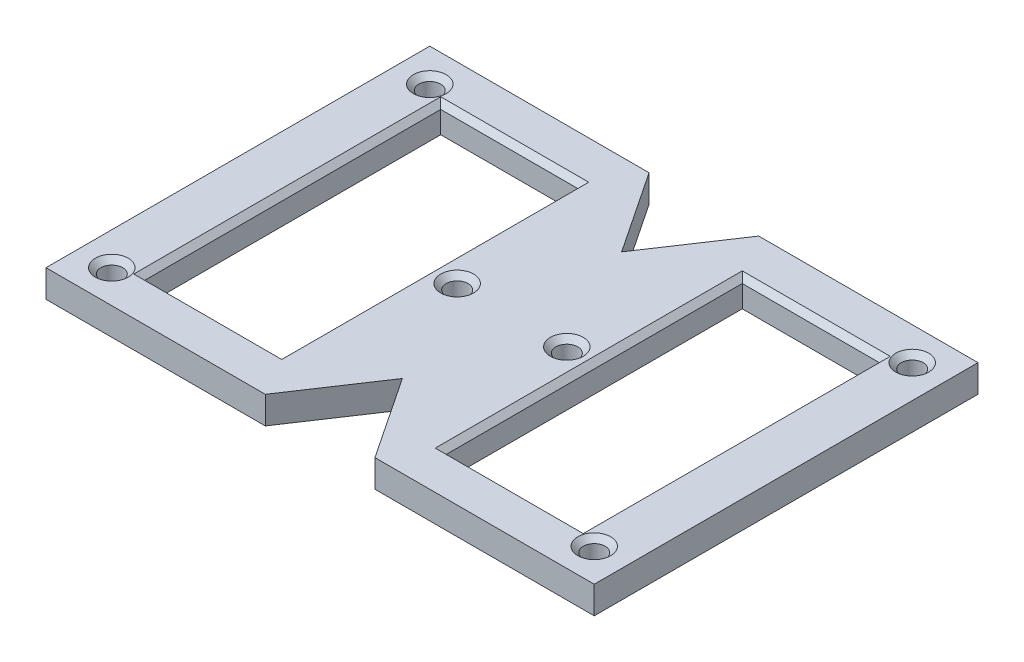
from build123d import *

# Parameters (mm, degrees)
CROQUIS1_W              = 100
CROQUIS1_H              = 70
SALIENTE_EXTRUIR1_DEPTH = 5
CROQUIS3_R              = 2
CORTAR_EXTRUIR2_DEPTH   = 6
CROQUIS6_R              = 2
CORTAR_EXTRUIR3_DEPTH   = 6
CROQUIS7_W              = 25
CROQUIS7_H              = 54
CORTAR_EXTRUIR4_DEPTH   = 6
CORTAR_EXTRUIR5_DEPTH   = 6
CHAFL_N1_SIZE           = 1


with BuildPart() as part:
    # Croquis1 → Saliente-Extruir1 (new body)
    with BuildSketch(Plane(origin=(0, 0, 0), x_dir=(1, 0, 0), z_dir=(0, 1, 0))):
        Rectangle(CROQUIS1_W, CROQUIS1_H)
    extrude(amount=SALIENTE_EXTRUIR1_DEPTH)

    # Croquis3 → Cortar-Extruir2 (cut, through all)
    with BuildSketch(Plane(origin=(0, 5, 0), x_dir=(1, 0, 0), z_dir=(0, 1, 0))):
        with Locations((-44, 29)):
            Circle(CROQUIS3_R)
        with Locations((44, 29)):
            Circle(CROQUIS3_R)
        with Locations((44, -29)):
            Circle(CROQUIS3_R)
        with Locations((-44, -29)):
            Circle(CROQUIS3_R)
    extrude(amount=-CORTAR_EXTRUIR2_DEPTH, mode=Mode.SUBTRACT)

    # Croquis6 → Cortar-Extruir3 (cut, through all)
    with BuildSketch(Plane(origin=(0, 5, 0), x_dir=(1, 0, 0), z_dir=(0, 1, 0))):
        with Locations((-10, 0)):
            Circle(CROQUIS6_R)
        with Locations((10, 0)):
            Circle(CROQUIS6_R)
    extrude(amount=-CORTAR_EXTRUIR3_DEPTH, mode=Mode.SUBTRACT)

    # Croquis7 → Cortar-Extruir4 (cut, through all)
    with BuildSketch(Plane.XZ):
        with Locations((-27.5, 0)):
            Rectangle(CROQUIS7_W, CROQUIS7_H)
        with Locations((27.5, 0)):
            Rectangle(CROQUIS7_W, CROQUIS7_H)
    extrude(amount=-CORTAR_EXTRUIR4_DEPTH, mode=Mode.SUBTRACT)

    # Croquis8 → Cortar-Extruir5 (cut, through all)
    with BuildSketch(Plane(origin=(0, 5, 0), x_dir=(1, 0, 0), z_dir=(0, 1, 0))):
        Polygon((-10, 35), (0, 20), (10, 35), align=None)
    cortar_extruir5 = extrude(amount=-CORTAR_EXTRUIR5_DEPTH, mode=Mode.SUBTRACT)

    # Simetría1: Cortar-Extruir5 across plane
    add(cortar_extruir5.mirror(Plane.XY), mode=Mode.SUBTRACT)

    # Chaflán1
    chafl_n1_edges = [part.edges().sort_by_distance(p)[0] for p in [
        (-46, 5, 29),
        (42, 5, 29),
        (42, 5, -29),
        (-46, 5, -29),
        (-12, 5, 0),
        (8, 5, 0),
        (-15, 5, 0),
        (-27.5, 5, -27),
        (-40, 5, 0),
        (-27.5, 5, 27),
        (40, 5, 0),
        (27.5, 5, -27),
        (15, 5, 0),
        (27.5, 5, 27),
    ]]
    chamfer(chafl_n1_edges, length=CHAFL_N1_SIZE)


solid = part.part
